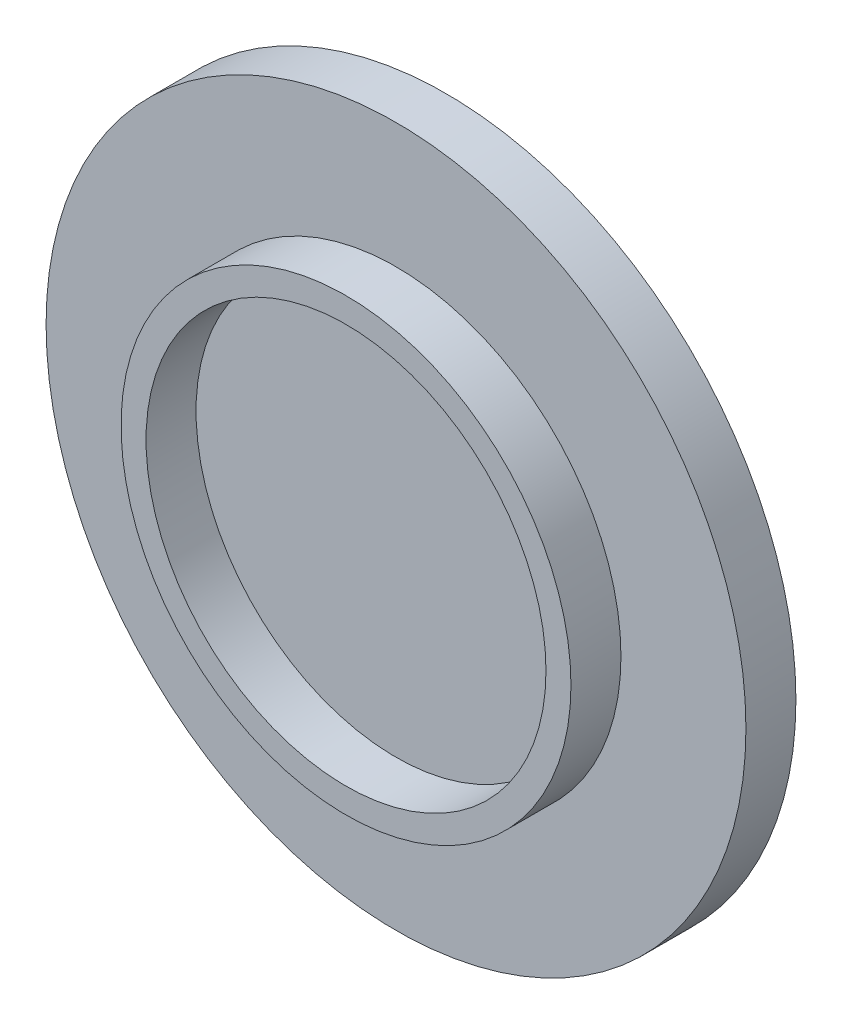
from build123d import *

# Parameters (mm, degrees)
SZKIC1_R                    = 70
DODANIE_WYCI_GNI_CIE1_DEPTH = 10
SZKIC2_R                    = 45
DODANIE_WYCI_GNI_CIE2_DEPTH = 10
SZKIC3_R                    = 40
WYTNIJ_WYCI_GNI_CIE1_DEPTH  = 10


with BuildPart() as part:
    # Szkic1 → Dodanie-wyciągnięcie1 (new body)
    with BuildSketch(Plane.XY):
        Circle(SZKIC1_R)
    extrude(amount=DODANIE_WYCI_GNI_CIE1_DEPTH)

    # Szkic2 → Dodanie-wyciągnięcie2 (add)
    with BuildSketch(Plane.XY.offset(10)):
        Circle(SZKIC2_R)
    extrude(amount=DODANIE_WYCI_GNI_CIE2_DEPTH)

    # Szkic3 → Wytnij-wyciągnięcie1 (cut)
    with BuildSketch(Plane.XY.offset(20)):
        Circle(SZKIC3_R)
    extrude(amount=-WYTNIJ_WYCI_GNI_CIE1_DEPTH, mode=Mode.SUBTRACT)


solid = part.part
